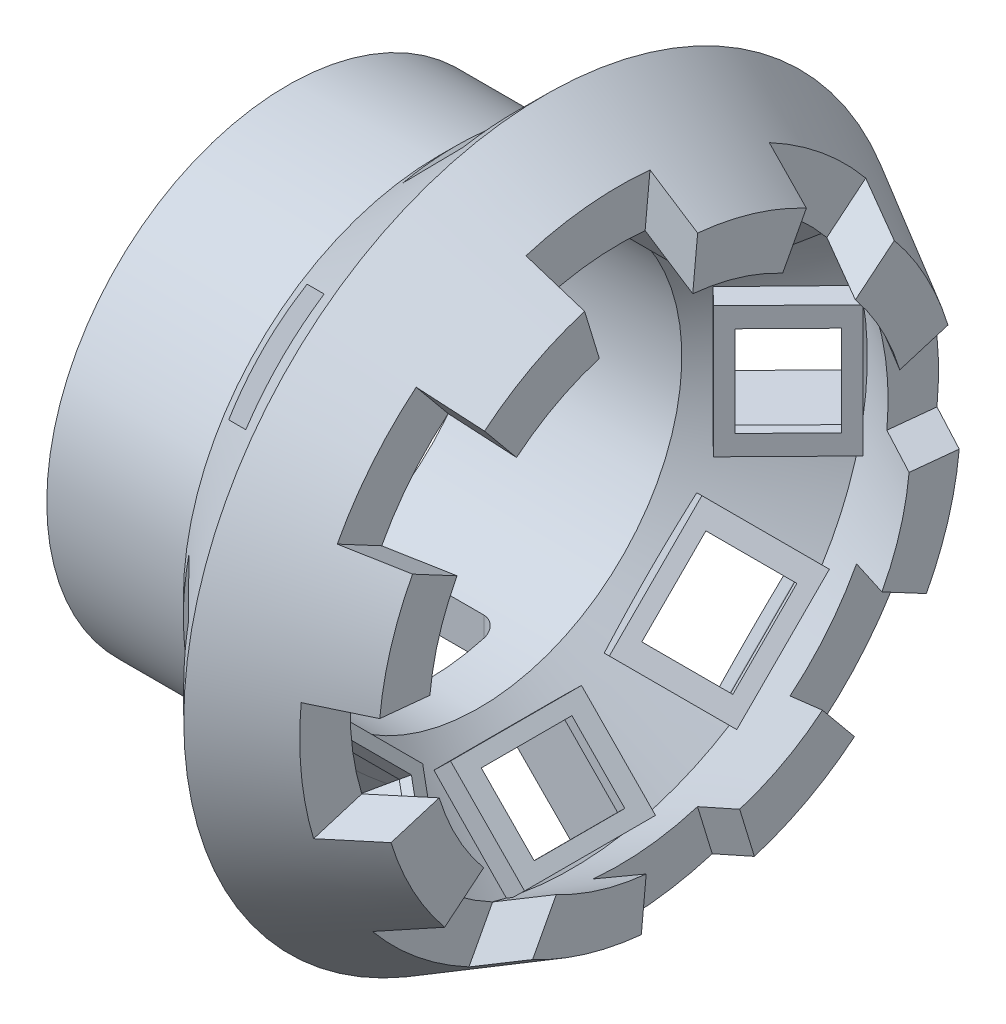
from build123d import *

# Parameters (mm, degrees)
CUT_EXTRUDE_1_DEPTH      = 1.1
PATTERN_CIRCULAR_1_COUNT = 8
SKETCH_6_W               = 5.893961657
SKETCH_6_H               = 11.227162516
SKETCH_6_W_2             = 3.517557102
SKETCH_6_H_2             = 15.129652159
CUT_EXTRUDE_2_DEPTH      = 10
SKETCH_7_W               = 2.6
SKETCH_7_H               = 2.100083765
SKETCH_7_W_2             = 2.2
SKETCH_7_H_2             = 1.700083765
EXTRUDE_1_DEPTH          = 0.3
SKETCH_11_W              = 2.6
SKETCH_11_H              = 2.100083765
SKETCH_11_W_2            = 1.8
SKETCH_11_H_2            = 1.500083765
EXTRUDE_2_DEPTH          = 0.2
PATTERN_CIRCULAR_2_COUNT = 8
CUT_EXTRUDE_3_DEPTH      = 1
SKETCH_10_W              = 2.8
SKETCH_10_H              = 4.363066302
CUT_EXTRUDE_4_DEPTH      = 2.8
FILLET_1_R               = 0.3


with BuildPart() as part:
    # 草图1 → 旋转1 (revolve)
    with BuildSketch(Plane.XY):
        Polygon((8.064664367, 7.169467647), (11.04001847, 5.5), (11.04001847, 4.5), (8.600815036, 5.868634144), (6.754967964, 4.03), (6.050341839, 4.03), (2.954967964, 4.03), (2.954967964, 4.78), (5.954967964, 4.78), (5.954967964, 5.068015203), align=None)
    revolve(axis=Axis((0, 0, 0), (1, 0, 0)))

    # 草图2 → 切除-拉伸1 (cut, symmetric)
    with BuildSketch(Plane(origin=(0, 0, 0), x_dir=(1, 0, 0), z_dir=(0, 1, 0))):
        Polygon((5.180344488, -6.508182903), (7.398791823, -4.289735569), (8.600873351, -5.491817097), (6.382426016, -7.710264431), align=None)
    cut_extrude_1 = extrude(amount=CUT_EXTRUDE_1_DEPTH, both=True, mode=Mode.SUBTRACT)

    # 阵列(圆周)1: 切除-拉伸1 ×8 about axis
    pattern_circular_1_axis = Axis((0, 0, 0), (1, 0, 0))
    for i in range(1, PATTERN_CIRCULAR_1_COUNT):
        add(cut_extrude_1.rotate(pattern_circular_1_axis, i * 360 / PATTERN_CIRCULAR_1_COUNT), mode=Mode.SUBTRACT)

    # 草图6 → 切除-拉伸2 (cut, symmetric)
    with BuildSketch(Plane.XY):
        with Locations((0.007987136, 0.100063837)):
            Rectangle(SKETCH_6_W, SKETCH_6_H)
        with Locations((12.298797021, -0.150095755)):
            Rectangle(SKETCH_6_W_2, SKETCH_6_H_2)
    extrude(amount=CUT_EXTRUDE_2_DEPTH, both=True, mode=Mode.SUBTRACT)

    # 草图7 → 凸台-拉伸1 (add, symmetric)
    with BuildSketch(Plane(origin=(1.503662278, -1.474101418, 0), x_dir=(0, 0, 1), z_dir=(-0.714091187, 0.700052696, 0))):
        with Locations((0, 9.094582396)):
            Rectangle(SKETCH_7_W, SKETCH_7_H)
        with Locations((0, 9.094582396)):
            Rectangle(SKETCH_7_W_2, SKETCH_7_H_2, mode=Mode.SUBTRACT)
    extrude_1 = extrude(amount=EXTRUDE_1_DEPTH, both=True)

    # 草图11 → 凸台-拉伸2 (add)
    with BuildSketch(Plane(origin=(1.717889634, -1.684117227, 0), x_dir=(0, 0, -1), z_dir=(0.714091187, -0.700052696, 0))):
        with Locations((0, 9.094582396)):
            Rectangle(SKETCH_11_W, SKETCH_11_H)
        with Locations((0, 9.094582396)):
            Rectangle(SKETCH_11_W_2, SKETCH_11_H_2, mode=Mode.SUBTRACT)
    extrude_2 = extrude(amount=EXTRUDE_2_DEPTH)

    # 阵列(圆周)2: 凸台-拉伸1, 凸台-拉伸2 ×8 about axis
    pattern_circular_2_axis = Axis((0, 0, 0), (1, 0, 0))
    for i in range(1, PATTERN_CIRCULAR_2_COUNT):
        add(extrude_1.rotate(pattern_circular_2_axis, i * 360 / PATTERN_CIRCULAR_2_COUNT))
        add(extrude_2.rotate(pattern_circular_2_axis, i * 360 / PATTERN_CIRCULAR_2_COUNT))

    # 草图9 → 切除-拉伸3 (cut)
    with BuildSketch(Plane(origin=(10.54001847, 0, 0), x_dir=(0, 0, -1), z_dir=(1, 0, 0))):
        with BuildLine():
            Line((-2.197785116, 7.210789857), (0, 0))
            Line((0, 0), (0.728961128, 7.502957114))
            ThreePointArc((0.728961128, 7.502957114), (-0.748799976, 7.501003158), (-2.197785116, 7.210789857))
        make_face()
        with BuildLine():
            Line((3.544729647, 6.652867165), (0, 0))
            Line((0, 0), (5.820845211, 4.789938498))
            ThreePointArc((5.820845211, 4.789938498), (4.774528658, 5.833491739), (3.544729647, 6.652867165))
        make_face()
        with BuildLine():
            Line((7.210789857, 2.197785116), (0, 0))
            Line((0, 0), (7.502957114, -0.728961128))
            ThreePointArc((7.502957114, -0.728961128), (7.501003158, 0.748799976), (7.210789857, 2.197785116))
        make_face()
        with BuildLine():
            Line((6.652867165, -3.544729647), (0, 0))
            Line((0, 0), (4.789938498, -5.820845211))
            ThreePointArc((4.789938498, -5.820845211), (5.833491739, -4.774528658), (6.652867165, -3.544729647))
        make_face()
        with BuildLine():
            Line((2.197785116, -7.210789857), (0, 0))
            Line((0, 0), (-0.728961128, -7.502957114))
            ThreePointArc((-0.728961128, -7.502957114), (0.748799976, -7.501003158), (2.197785116, -7.210789857))
        make_face()
        with BuildLine():
            Line((-3.544729647, -6.652867165), (0, 0))
            Line((0, 0), (-5.820845211, -4.789938498))
            ThreePointArc((-5.820845211, -4.789938498), (-4.774528658, -5.833491739), (-3.544729647, -6.652867165))
        make_face()
        with BuildLine():
            Line((-7.210789857, -2.197785116), (0, 0))
            Line((0, 0), (-7.502957114, 0.728961128))
            ThreePointArc((-7.502957114, 0.728961128), (-7.501003158, -0.748799976), (-7.210789857, -2.197785116))
        make_face()
        with BuildLine():
            Line((-6.652867165, 3.544729647), (0, 0))
            Line((0, 0), (-4.789938498, 5.820845211))
            ThreePointArc((-4.789938498, 5.820845211), (-5.833491739, 4.774528658), (-6.652867165, 3.544729647))
        make_face()
    extrude(amount=-CUT_EXTRUDE_3_DEPTH, mode=Mode.SUBTRACT)

    # 草图10 → 切除-拉伸4 (cut)
    with BuildSketch(Plane.ZY.offset(-2.954967964)):
        with Locations((0, -3.128262499)):
            Rectangle(SKETCH_10_W, SKETCH_10_H)
    extrude(amount=-CUT_EXTRUDE_4_DEPTH, mode=Mode.SUBTRACT)

    # 圆角1
    fillet_1_edges = [part.edges().sort_by_distance(p)[0] for p in [
        (2.954967964, -4.174695361, 1.4),
        (2.954967964, -4.174695361, -1.4),
        (5.754967964, -4.174695361, -1.4),
        (5.754967964, -4.174695361, 1.4),
    ]]
    fillet(fillet_1_edges, radius=FILLET_1_R)


solid = part.part
